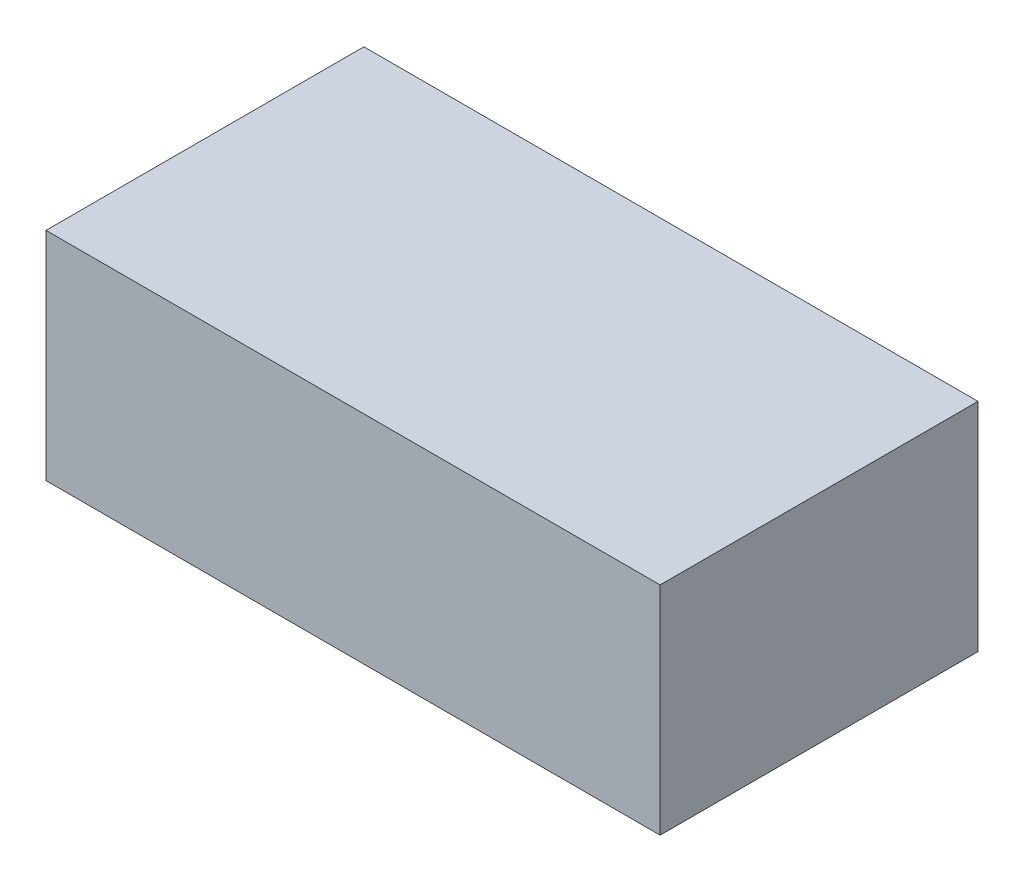
from build123d import *

# Parameters (mm, degrees)
SKETCH1_W           = 85
SKETCH1_H           = 44
BOSS_EXTRUDE1_DEPTH = 30


with BuildPart() as part:
    # Sketch1 → Boss-Extrude1 (new body)
    with BuildSketch(Plane(origin=(0, 0, 0), x_dir=(1, 0, 0), z_dir=(0, 1, 0))):
        with Locations((42.5, 22)):
            Rectangle(SKETCH1_W, SKETCH1_H)
    extrude(amount=BOSS_EXTRUDE1_DEPTH)


solid = part.part
